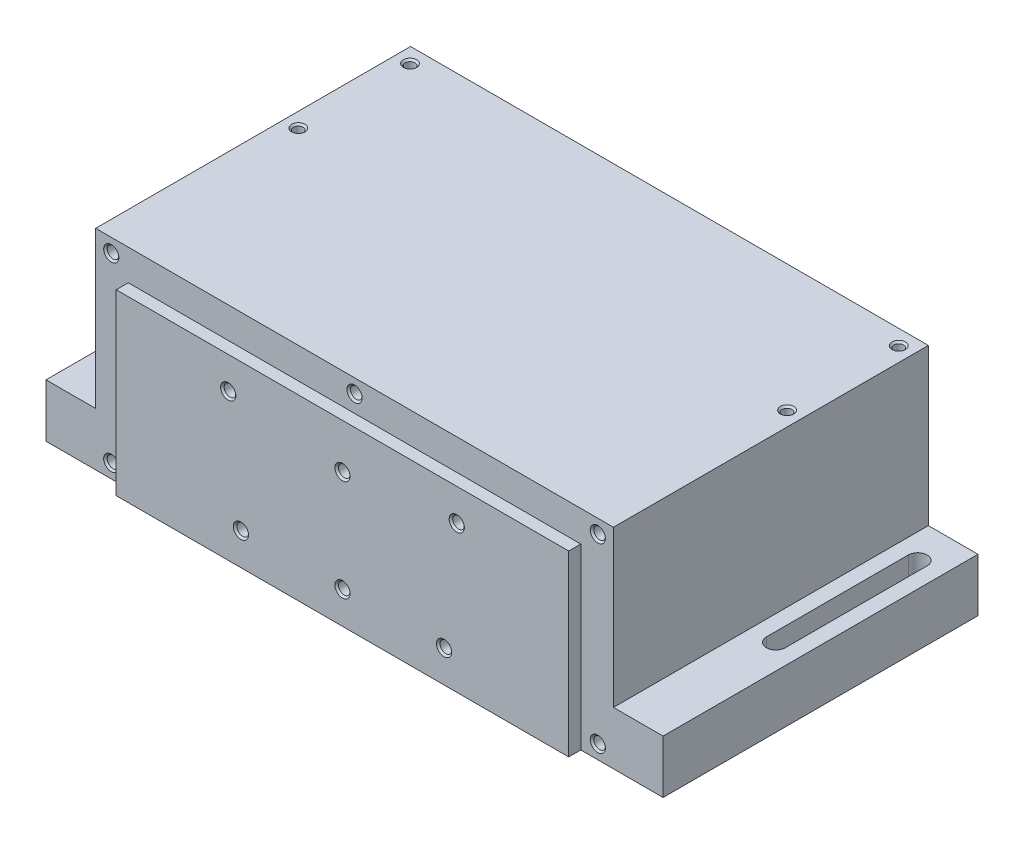
from build123d import *

# Parameters (mm, degrees)
BOSS_EXTRUDE1_DEPTH              = 50.8
F_6_32_TAPPED_HOLE1_AT_2_COUNT   = 2
F_6_32_TAPPED_HOLE1_AT_2_PITCH   = 40.005
F_6_32_TAPPED_HOLE1_AT_3_COUNT   = 2
F_6_32_TAPPED_HOLE1_AT_3_PITCH   = 179.52019402
F_6_32_TAPPED_HOLE1_AT_4_COUNT   = 2
F_6_32_TAPPED_HOLE1_AT_4_PITCH   = 175.006
BOSS_EXTRUDE2_DEPTH              = 61.976
CUT_EXTRUDE2_DEPTH               = 20.05
F_8_32_TAPPED_HOLE1_AT_2_COUNT   = 2
F_8_32_TAPPED_HOLE1_AT_2_PITCH   = 65.024
F_8_32_TAPPED_HOLE1_AT_3_COUNT   = 2
F_8_32_TAPPED_HOLE1_AT_3_PITCH   = 185.981429482
F_8_32_TAPPED_HOLE1_AT_4_COUNT   = 2
F_8_32_TAPPED_HOLE1_AT_4_PITCH   = 174.244
F_8_32_TAPPED_HOLE1_AT_5_COUNT   = 2
F_8_32_TAPPED_HOLE1_AT_5_PITCH   = 87.122
SKETCH13_W                       = 162.052
SKETCH13_H                       = 63.881
BOSS_EXTRUDE4_DEPTH              = 4.318
F_8_32_TAPPED_HOLE2_AT_2_COUNT   = 2
F_8_32_TAPPED_HOLE2_AT_2_PITCH   = 41.171214069
F_8_32_TAPPED_HOLE2_AT_3_COUNT   = 2
F_8_32_TAPPED_HOLE2_AT_3_PITCH   = 87.455597175
F_8_32_TAPPED_HOLE2_AT_4_COUNT   = 2
F_8_32_TAPPED_HOLE2_AT_4_PITCH   = 81.8388
F_8_32_TAPPED_HOLE2_AT_5_COUNT   = 2
F_8_32_TAPPED_HOLE2_AT_5_PITCH   = 57.868770444
F_8_32_TAPPED_HOLE2_AT_6_COUNT   = 2
F_8_32_TAPPED_HOLE2_AT_6_PITCH   = 41.171214069
CUT_EXTRUDE3_DEPTH               = 3.54
F_1_4_20_TAPPED_HOLE1_AT_2_COUNT = 2
F_1_4_20_TAPPED_HOLE1_AT_2_PITCH = 50.8


with BuildPart() as part:
    # Sketch1 → Boss-Extrude1 (new body)
    with BuildSketch(Plane.XY):
        Polygon((-92.71, 2.54), (92.71, 2.54), (92.71, 0), (110.49, 0), (110.49, 19.05), (92.71, 19.05), (92.71, 74.93), (-92.71, 74.93), (-92.71, 19.05), (-110.49, 19.05), (-110.49, 0), (-92.71, 0), align=None)
    extrude(amount=-BOSS_EXTRUDE1_DEPTH)

    # Sketch3 → #6-32 Tapped Hole1 (revolve, cut)
    with BuildSketch(Plane(origin=(-87.503, 74.93, -45.4025), x_dir=(0, 0, 1), z_dir=(1, 0, 0))):
        Polygon((0, 0), (0, 14.42709403), (1.35255, 13.6144), (1.35255, 9.652), (1.7526, 9.652), (1.7526, 0.635), (2.3876, 0), align=None)
    f_6_32_tapped_hole1 = revolve(axis=Axis((-87.503, 81.28, -45.4025), (0, -1, 0)), mode=Mode.SUBTRACT)

    # #6-32 Tapped Hole1 at 2: #6-32 Tapped Hole1 ×2
    with Locations(*[(0, 0, i * F_6_32_TAPPED_HOLE1_AT_2_PITCH) for i in range(1, F_6_32_TAPPED_HOLE1_AT_2_COUNT)]):
        add(f_6_32_tapped_hole1, mode=Mode.SUBTRACT)

    # #6-32 Tapped Hole1 at 3: #6-32 Tapped Hole1 ×2
    with Locations(*[Vector(0.974854116, 0, 0.22284401) * (i * F_6_32_TAPPED_HOLE1_AT_3_PITCH) for i in range(1, F_6_32_TAPPED_HOLE1_AT_3_COUNT)]):
        add(f_6_32_tapped_hole1, mode=Mode.SUBTRACT)

    # #6-32 Tapped Hole1 at 4: #6-32 Tapped Hole1 ×2
    with Locations(*[(i * F_6_32_TAPPED_HOLE1_AT_4_PITCH, 0, 0) for i in range(1, F_6_32_TAPPED_HOLE1_AT_4_COUNT)]):
        add(f_6_32_tapped_hole1, mode=Mode.SUBTRACT)

    # Sketch5 → Boss-Extrude2 (add)
    with BuildSketch(Plane.XY):
        Polygon((92.71, 74.93), (-92.71, 74.93), (-92.71, 19.05), (-110.49, 19.05), (-110.49, 0), (110.49, 0), (110.49, 19.05), (92.71, 19.05), align=None)
    extrude(amount=BOSS_EXTRUDE2_DEPTH)

    # Sketch16 → Cut-Extrude2 (cut, through all)
    with BuildSketch(Plane(origin=(0, 19.05, 0), x_dir=(1, 0, 0), z_dir=(0, 1, 0))):
        with BuildLine():
            Line((-104.9782, 38.1), (-104.9782, -12.7))
            ThreePointArc((-104.9782, -12.7), (-101.6, -16.0782), (-98.2218, -12.7))
            Line((-98.2218, -12.7), (-98.2218, 38.1))
            ThreePointArc((-98.2218, 38.1), (-101.6, 41.4782), (-104.9782, 38.1))
        make_face()
        with BuildLine():
            Line((104.9782, 38.1), (104.9782, -12.7))
            ThreePointArc((104.9782, -12.7), (101.6, -16.0782), (98.2218, -12.7))
            Line((98.2218, -12.7), (98.2218, 38.1))
            ThreePointArc((98.2218, 38.1), (101.6, 41.4782), (104.9782, 38.1))
        make_face()
    extrude(amount=-CUT_EXTRUDE2_DEPTH, mode=Mode.SUBTRACT)

    # Sketch11 → #8-32 Tapped Hole1 (revolve, cut)
    with BuildSketch(Plane(origin=(-87.122, 69.977, 61.976), x_dir=(0, -1, 0), z_dir=(1, 0, 0))):
        Polygon((0, 0), (0, 17.700206461), (1.7272, 16.6624), (1.7272, 12.7), (2.0828, 12.7), (2.0828, 0.635), (2.7178, 0), align=None)
    f_8_32_tapped_hole1 = revolve(axis=Axis((-87.122, 69.977, 68.326), (0, 0, -1)), mode=Mode.SUBTRACT)

    # #8-32 Tapped Hole1 at 2: #8-32 Tapped Hole1 ×2
    with Locations(*[(0, -i * F_8_32_TAPPED_HOLE1_AT_2_PITCH, 0) for i in range(1, F_8_32_TAPPED_HOLE1_AT_2_COUNT)]):
        add(f_8_32_tapped_hole1, mode=Mode.SUBTRACT)

    # #8-32 Tapped Hole1 at 3: #8-32 Tapped Hole1 ×2
    with Locations(*[Vector(0.936889239, -0.349626305, 0) * (i * F_8_32_TAPPED_HOLE1_AT_3_PITCH) for i in range(1, F_8_32_TAPPED_HOLE1_AT_3_COUNT)]):
        add(f_8_32_tapped_hole1, mode=Mode.SUBTRACT)

    # #8-32 Tapped Hole1 at 4: #8-32 Tapped Hole1 ×2
    with Locations(*[(i * F_8_32_TAPPED_HOLE1_AT_4_PITCH, 0, 0) for i in range(1, F_8_32_TAPPED_HOLE1_AT_4_COUNT)]):
        add(f_8_32_tapped_hole1, mode=Mode.SUBTRACT)

    # #8-32 Tapped Hole1 at 5: #8-32 Tapped Hole1 ×2
    with Locations(*[(i * F_8_32_TAPPED_HOLE1_AT_5_PITCH, 0, 0) for i in range(1, F_8_32_TAPPED_HOLE1_AT_5_COUNT)]):
        add(f_8_32_tapped_hole1, mode=Mode.SUBTRACT)

    # Sketch13 → Boss-Extrude4 (add)
    with BuildSketch(Plane.XY.offset(61.976)):
        with Locations((0, 31.9405)):
            Rectangle(SKETCH13_W, SKETCH13_H)
    extrude(amount=BOSS_EXTRUDE4_DEPTH)

    # Sketch7 → #8-32 Tapped Hole2 (revolve, cut)
    with BuildSketch(Plane(origin=(-40.9194, 52.4002, 66.294), x_dir=(0, -1, 0), z_dir=(1, 0, 0))):
        Polygon((0, 0), (0, 17.700206461), (1.7272, 16.6624), (1.7272, 12.7), (2.0828, 12.7), (2.0828, 0.635), (2.7178, 0), align=None)
    f_8_32_tapped_hole2 = revolve(axis=Axis((-40.9194, 52.4002, 72.644), (0, 0, -1)), mode=Mode.SUBTRACT)

    # #8-32 Tapped Hole2 at 2: #8-32 Tapped Hole2 ×2
    with Locations(*[Vector(0.110431526, -0.993883735, 0) * (i * F_8_32_TAPPED_HOLE2_AT_2_PITCH) for i in range(1, F_8_32_TAPPED_HOLE2_AT_2_COUNT)]):
        add(f_8_32_tapped_hole2, mode=Mode.SUBTRACT)

    # #8-32 Tapped Hole2 at 3: #8-32 Tapped Hole2 ×2
    with Locations(*[Vector(0.883787916, -0.46788772, 0) * (i * F_8_32_TAPPED_HOLE2_AT_3_PITCH) for i in range(1, F_8_32_TAPPED_HOLE2_AT_3_COUNT)]):
        add(f_8_32_tapped_hole2, mode=Mode.SUBTRACT)

    # #8-32 Tapped Hole2 at 4: #8-32 Tapped Hole2 ×2
    with Locations(*[(i * F_8_32_TAPPED_HOLE2_AT_4_PITCH, 0, 0) for i in range(1, F_8_32_TAPPED_HOLE2_AT_4_COUNT)]):
        add(f_8_32_tapped_hole2, mode=Mode.SUBTRACT)

    # #8-32 Tapped Hole2 at 5: #8-32 Tapped Hole2 ×2
    with Locations(*[Vector(0.707106781, -0.707106781, 0) * (i * F_8_32_TAPPED_HOLE2_AT_5_PITCH) for i in range(1, F_8_32_TAPPED_HOLE2_AT_5_COUNT)]):
        add(f_8_32_tapped_hole2, mode=Mode.SUBTRACT)

    # #8-32 Tapped Hole2 at 6: #8-32 Tapped Hole2 ×2
    with Locations(*[Vector(0.993883735, -0.110431526, 0) * (i * F_8_32_TAPPED_HOLE2_AT_6_PITCH) for i in range(1, F_8_32_TAPPED_HOLE2_AT_6_COUNT)]):
        add(f_8_32_tapped_hole2, mode=Mode.SUBTRACT)

    # Sketch17 → Cut-Extrude3 (cut, through all)
    with BuildSketch(Plane.XZ.offset(-2.54)):
        with BuildLine():
            Line((-92.71, 0), (92.71, 0))
            Line((92.71, 0), (92.71, 49.403))
            ThreePointArc((92.71, 49.403), (89.920192091, 56.138192091), (83.185, 58.928))
            Line((83.185, 58.928), (-83.185, 58.928))
            ThreePointArc((-83.185, 58.928), (-89.920192091, 56.138192091), (-92.71, 49.403))
            Line((-92.71, 49.403), (-92.71, 0))
        make_face()
    extrude(amount=CUT_EXTRUDE3_DEPTH, mode=Mode.SUBTRACT)

    # Sketch18 → 1/4-20 Tapped Hole1 (revolve, cut)
    with BuildSketch(Plane(origin=(25.4, 38.1, -50.8), x_dir=(0, 1, 0), z_dir=(1, 0, 0))):
        Polygon((0, 0), (0, 20.583816902), (2.5527, 19.05), (2.5527, 12.7), (3.175, 12.7), (3.175, 0.762), (3.937, 0), align=None)
    f_1_4_20_tapped_hole1 = revolve(axis=Axis((25.4, 38.1, -57.15), (0, 0, 1)), mode=Mode.SUBTRACT)

    # 1/4-20 Tapped Hole1 at 2: 1/4-20 Tapped Hole1 ×2
    with Locations(*[(-i * F_1_4_20_TAPPED_HOLE1_AT_2_PITCH, 0, 0) for i in range(1, F_1_4_20_TAPPED_HOLE1_AT_2_COUNT)]):
        add(f_1_4_20_tapped_hole1, mode=Mode.SUBTRACT)


solid = part.part
